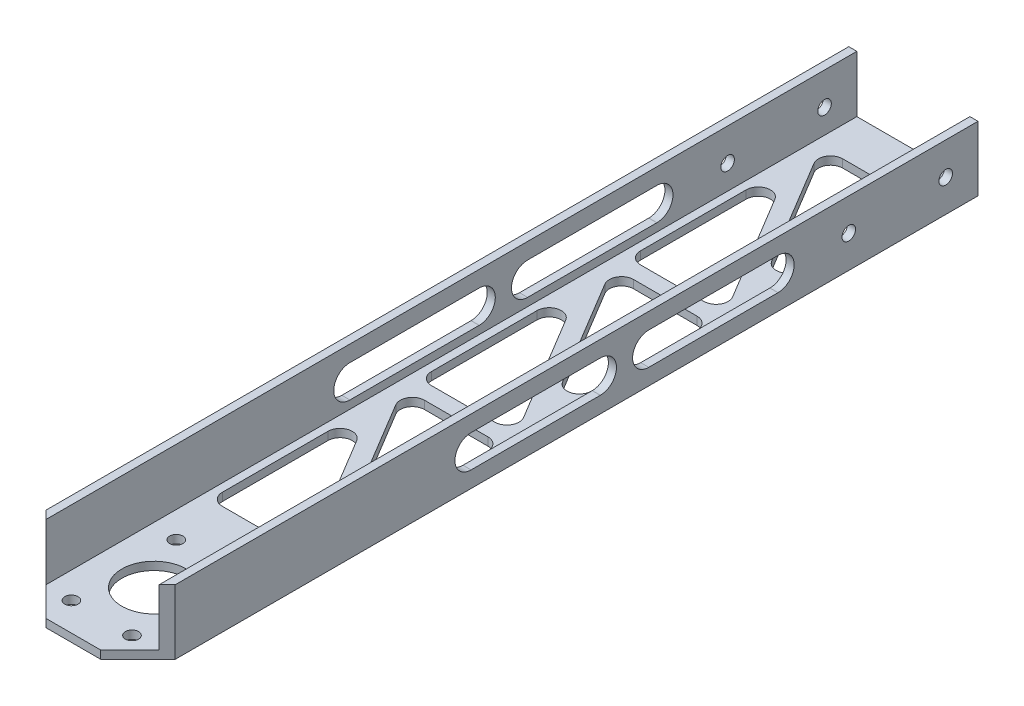
from build123d import *

# Parameters (mm, degrees)
BOSS_EXTRUDE1_DEPTH = 330.2
CUT_EXTRUDE1_REACH  = 27.4
SKETCH2_R           = 12.7
SKETCH3_R           = 2.667
CUT_EXTRUDE2_DEPTH  = 51.8
CUT_EXTRUDE3_REACH  = 27.4
SKETCH4_R           = 2.5908
CUT_EXTRUDE4_REACH  = 27.4
CUT_EXTRUDE5_DEPTH  = 51.8
CUT_EXTRUDE6_DEPTH  = 26.4


with BuildPart() as part:
    # Sketch1 → Boss-Extrude1 (new body)
    with BuildSketch(Plane.XY):
        Polygon((47.625, 3.175), (47.625, 25.4), (50.8, 25.4), (50.8, 0), (0, 0), (0, 25.4), (3.175, 25.4), (3.175, 3.175), align=None)
    extrude(amount=BOSS_EXTRUDE1_DEPTH)

    # Sketch2 → Cut-Extrude1 (cut, up to next)
    with BuildSketch(Plane.XZ, mode=Mode.PRIVATE) as cut_extrude1_sk1:
        with Locations((25.4, 298.45)):
            Circle(SKETCH2_R)
    cut_extrude1_tool1 = extrude(cut_extrude1_sk1.sketch, amount=-CUT_EXTRUDE1_REACH, mode=Mode.PRIVATE) & part.part
    add(cut_extrude1_tool1.solids().sort_by_distance((25.4, 0, 298.45))[0], mode=Mode.SUBTRACT)

    # Sketch3 → Cut-Extrude2 (cut, through all)
    with BuildSketch(Plane(origin=(50.8, 0, 0), x_dir=(0, 0, -1), z_dir=(1, 0, 0))):
        with Locations((-12.7, 12.7)):
            Circle(SKETCH3_R)
        with Locations((-50.8, 12.7)):
            Circle(SKETCH3_R)
    extrude(amount=-CUT_EXTRUDE2_DEPTH, mode=Mode.SUBTRACT)

    # Sketch4 → Cut-Extrude3 (cut, up to next)
    with BuildSketch(Plane.XZ, mode=Mode.PRIVATE) as cut_extrude3_sk1:
        with Locations((13.49375, 277.827770072)):
            Circle(SKETCH4_R)
    cut_extrude3_tool1 = extrude(cut_extrude3_sk1.sketch, amount=-CUT_EXTRUDE3_REACH, mode=Mode.PRIVATE) & part.part
    add(cut_extrude3_tool1.solids().sort_by_distance((13.49375, 0, 277.82777))[0], mode=Mode.SUBTRACT)
    # Sketch4 → Cut-Extrude3 (cut, up to next)
    with BuildSketch(Plane.XZ, mode=Mode.PRIVATE) as cut_extrude3_sk2:
        with Locations((37.30625, 277.827770072)):
            Circle(SKETCH4_R)
    cut_extrude3_tool2 = extrude(cut_extrude3_sk2.sketch, amount=-CUT_EXTRUDE3_REACH, mode=Mode.PRIVATE) & part.part
    add(cut_extrude3_tool2.solids().sort_by_distance((37.30625, 0, 277.82777))[0], mode=Mode.SUBTRACT)
    # Sketch4 → Cut-Extrude3 (cut, up to next)
    with BuildSketch(Plane.XZ, mode=Mode.PRIVATE) as cut_extrude3_sk3:
        with Locations((13.49375, 319.072229928)):
            Circle(SKETCH4_R)
    cut_extrude3_tool3 = extrude(cut_extrude3_sk3.sketch, amount=-CUT_EXTRUDE3_REACH, mode=Mode.PRIVATE) & part.part
    add(cut_extrude3_tool3.solids().sort_by_distance((13.49375, 0, 319.07223))[0], mode=Mode.SUBTRACT)
    # Sketch4 → Cut-Extrude3 (cut, up to next)
    with BuildSketch(Plane.XZ, mode=Mode.PRIVATE) as cut_extrude3_sk4:
        with Locations((37.30625, 319.072229928)):
            Circle(SKETCH4_R)
    cut_extrude3_tool4 = extrude(cut_extrude3_sk4.sketch, amount=-CUT_EXTRUDE3_REACH, mode=Mode.PRIVATE) & part.part
    add(cut_extrude3_tool4.solids().sort_by_distance((37.30625, 0, 319.07223))[0], mode=Mode.SUBTRACT)

    # Sketch5 → Cut-Extrude4 (cut, up to next)
    with BuildSketch(Plane.XZ, mode=Mode.PRIVATE) as cut_extrude4_sk1:
        with BuildLine():
            Line((40.122328379, 85.773383183), (15.196310059, 44.230019316))
            ThreePointArc((15.196310059, 44.230019316), (9.841228816, 42.090613006), (6.35, 46.680305352))
            Line((6.35, 46.680305352), (6.35, 88.223669219))
            ThreePointArc((6.35, 88.223669219), (7.744903955, 91.591265264), (11.1125, 92.986169219))
            Line((11.1125, 92.986169219), (36.03851832, 92.986169219))
            ThreePointArc((36.03851832, 92.986169219), (40.182845376, 90.570147325), (40.122328379, 85.773383183))
        make_face()
    cut_extrude4_tool1 = extrude(cut_extrude4_sk1.sketch, amount=-CUT_EXTRUDE4_REACH, mode=Mode.PRIVATE) & part.part
    add(cut_extrude4_tool1.solids().sort_by_distance((19.256233, 0, 73.00095))[0], mode=Mode.SUBTRACT)
    # Sketch5 → Cut-Extrude4 (cut, up to next)
    with BuildSketch(Plane.XZ, mode=Mode.PRIVATE) as cut_extrude4_sk2:
        with BuildLine():
            Line((14.76148168, 17.143987708), (39.6875, 17.143987708))
            ThreePointArc((39.6875, 17.143987708), (43.055096045, 18.538891662), (44.45, 21.906487708))
            Line((44.45, 21.906487708), (44.45, 63.449851575))
            ThreePointArc((44.45, 63.449851575), (40.958771184, 68.03954392), (35.603689941, 65.90013761))
            Line((35.603689941, 65.90013761), (10.677671621, 24.356773743))
            ThreePointArc((10.677671621, 24.356773743), (10.617154624, 19.560009601), (14.76148168, 17.143987708))
        make_face()
    cut_extrude4_tool2 = extrude(cut_extrude4_sk2.sketch, amount=-CUT_EXTRUDE4_REACH, mode=Mode.PRIVATE) & part.part
    add(cut_extrude4_tool2.solids().sort_by_distance((31.543767, 0, 37.129207))[0], mode=Mode.SUBTRACT)
    # Sketch5 → Cut-Extrude4 (cut, up to next)
    with BuildSketch(Plane.XZ, mode=Mode.PRIVATE) as cut_extrude4_sk3:
        with BuildLine():
            Line((40.122328379, 167.965564694), (15.196310059, 126.422200827))
            ThreePointArc((15.196310059, 126.422200827), (9.841228816, 124.282794517), (6.35, 128.872486862))
            Line((6.35, 128.872486862), (6.35, 170.415850729))
            ThreePointArc((6.35, 170.415850729), (7.744903955, 173.783446775), (11.1125, 175.178350729))
            Line((11.1125, 175.178350729), (36.03851832, 175.178350729))
            ThreePointArc((36.03851832, 175.178350729), (40.182845376, 172.762328836), (40.122328379, 167.965564694))
        make_face()
    cut_extrude4_tool3 = extrude(cut_extrude4_sk3.sketch, amount=-CUT_EXTRUDE4_REACH, mode=Mode.PRIVATE) & part.part
    add(cut_extrude4_tool3.solids().sort_by_distance((19.256233, 0, 155.193132))[0], mode=Mode.SUBTRACT)
    # Sketch5 → Cut-Extrude4 (cut, up to next)
    with BuildSketch(Plane.XZ, mode=Mode.PRIVATE) as cut_extrude4_sk4:
        with BuildLine():
            Line((14.76148168, 99.336169219), (39.6875, 99.336169219))
            ThreePointArc((39.6875, 99.336169219), (43.055096045, 100.731073173), (44.45, 104.098669219))
            Line((44.45, 104.098669219), (44.45, 145.642033085))
            ThreePointArc((44.45, 145.642033085), (40.958771184, 150.231725431), (35.603689941, 148.092319121))
            Line((35.603689941, 148.092319121), (10.677671621, 106.548955254))
            ThreePointArc((10.677671621, 106.548955254), (10.617154624, 101.752191112), (14.76148168, 99.336169219))
        make_face()
    cut_extrude4_tool4 = extrude(cut_extrude4_sk4.sketch, amount=-CUT_EXTRUDE4_REACH, mode=Mode.PRIVATE) & part.part
    add(cut_extrude4_tool4.solids().sort_by_distance((31.543767, 0, 119.321388))[0], mode=Mode.SUBTRACT)
    # Sketch5 → Cut-Extrude4 (cut, up to next)
    with BuildSketch(Plane.XZ, mode=Mode.PRIVATE) as cut_extrude4_sk5:
        with BuildLine():
            Line((40.122328379, 250.157746205), (15.196310059, 208.614382338))
            ThreePointArc((15.196310059, 208.614382338), (9.841228816, 206.474976028), (6.35, 211.064668373))
            Line((6.35, 211.064668373), (6.35, 252.60803224))
            ThreePointArc((6.35, 252.60803224), (7.744903955, 255.975628285), (11.1125, 257.37053224))
            Line((11.1125, 257.37053224), (36.03851832, 257.37053224))
            ThreePointArc((36.03851832, 257.37053224), (40.182845376, 254.954510346), (40.122328379, 250.157746205))
        make_face()
    cut_extrude4_tool5 = extrude(cut_extrude4_sk5.sketch, amount=-CUT_EXTRUDE4_REACH, mode=Mode.PRIVATE) & part.part
    add(cut_extrude4_tool5.solids().sort_by_distance((19.256233, 0, 237.385313))[0], mode=Mode.SUBTRACT)
    # Sketch5 → Cut-Extrude4 (cut, up to next)
    with BuildSketch(Plane.XZ, mode=Mode.PRIVATE) as cut_extrude4_sk6:
        with BuildLine():
            Line((14.76148168, 181.528350729), (39.6875, 181.528350729))
            ThreePointArc((39.6875, 181.528350729), (43.055096045, 182.923254684), (44.45, 186.290850729))
            Line((44.45, 186.290850729), (44.45, 227.834214596))
            ThreePointArc((44.45, 227.834214596), (40.958771184, 232.423906942), (35.603689941, 230.284500631))
            Line((35.603689941, 230.284500631), (10.677671621, 188.741136765))
            ThreePointArc((10.677671621, 188.741136765), (10.617154624, 183.944372623), (14.76148168, 181.528350729))
        make_face()
    cut_extrude4_tool6 = extrude(cut_extrude4_sk6.sketch, amount=-CUT_EXTRUDE4_REACH, mode=Mode.PRIVATE) & part.part
    add(cut_extrude4_tool6.solids().sort_by_distance((31.543767, 0, 201.51357))[0], mode=Mode.SUBTRACT)

    # Sketch6 → Cut-Extrude5 (cut, through all)
    with BuildSketch(Plane.ZY):
        with BuildLine():
            Line((78.616971835, 19.05), (129.416971835, 19.05))
            ThreePointArc((129.416971835, 19.05), (135.766971835, 12.7), (129.416971835, 6.35))
            Line((129.416971835, 6.35), (78.616971835, 6.35))
            ThreePointArc((78.616971835, 6.35), (72.266971835, 12.7), (78.616971835, 19.05))
        make_face()
        with BuildLine():
            Line((148.466971835, 19.05), (199.266971835, 19.05))
            ThreePointArc((199.266971835, 19.05), (205.616971835, 12.7), (199.266971835, 6.35))
            Line((199.266971835, 6.35), (148.466971835, 6.35))
            ThreePointArc((148.466971835, 6.35), (142.116971835, 12.7), (148.466971835, 19.05))
        make_face()
    extrude(amount=-CUT_EXTRUDE5_DEPTH, mode=Mode.SUBTRACT)

    # Sketch7 → Cut-Extrude6 (cut, through all)
    with BuildSketch(Plane.XZ):
        Polygon((0, 330.2), (0, 315.558408634), (14.641591366, 330.2), align=None)
        Polygon((36.158408634, 330.2), (50.8, 330.2), (50.8, 315.558408634), align=None)
    extrude(amount=-CUT_EXTRUDE6_DEPTH, mode=Mode.SUBTRACT)


solid = part.part
